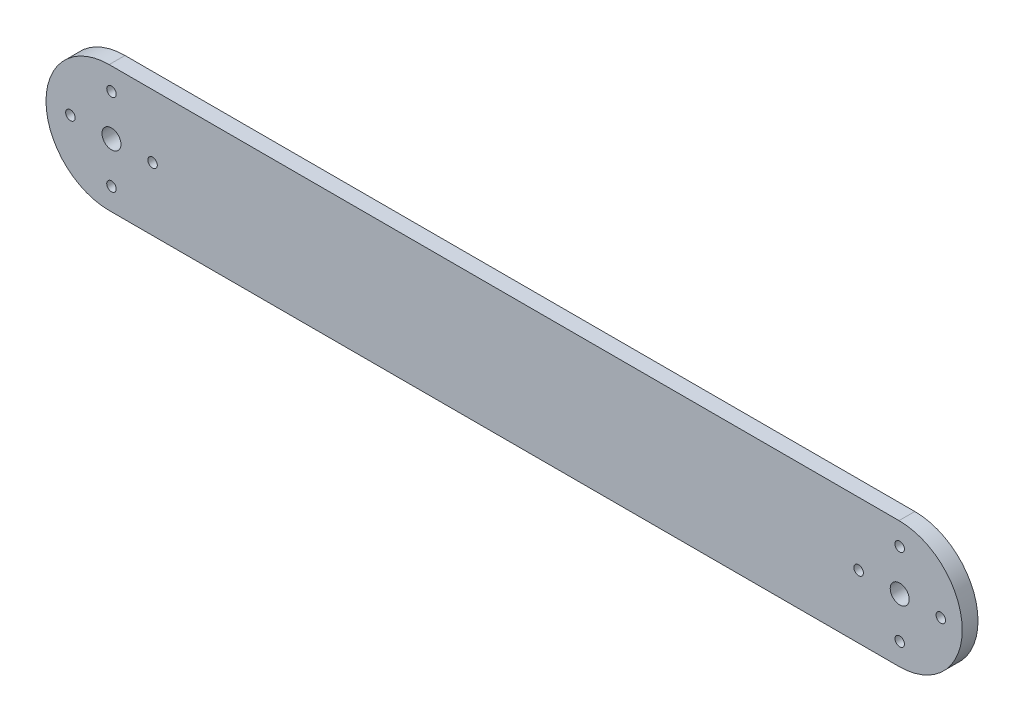
from build123d import *

# Parameters (mm, degrees)
BOSS_EXTRUDE1_DEPTH = 5
SKETCH2_R           = 1.5
CUT_EXTRUDE1_DEPTH  = 5
SKETCH3_R           = 3
CUT_EXTRUDE2_DEPTH  = 5
SKETCH4_R           = 3
CUT_EXTRUDE3_DEPTH  = 10


with BuildPart() as part:
    # Sketch1 → Boss-Extrude1 (new body)
    with BuildSketch(Plane.XY):
        with BuildLine():
            Line((125, -20), (-125, -20))
            ThreePointArc((-125, -20), (-145, 0), (-125, 20))
            Line((-125, 20), (125, 20))
            ThreePointArc((125, 20), (145, 0), (125, -20))
        make_face()
    extrude(amount=BOSS_EXTRUDE1_DEPTH)

    # Sketch2 → Cut-Extrude1 (cut)
    with BuildSketch(Plane.XY.offset(5)):
        with Locations((-124.274977314, 13)):
            Circle(SKETCH2_R)
        with Locations((-111.274977314, 0)):
            Circle(SKETCH2_R)
        with Locations((-124.274977314, -13)):
            Circle(SKETCH2_R)
        with Locations((-137.274977314, 0)):
            Circle(SKETCH2_R)
        with Locations((125.216266839, 13)):
            Circle(SKETCH2_R)
        with Locations((138.216266839, 0)):
            Circle(SKETCH2_R)
        with Locations((125.216266839, -13)):
            Circle(SKETCH2_R)
        with Locations((112.216266839, 0)):
            Circle(SKETCH2_R)
    extrude(amount=-CUT_EXTRUDE1_DEPTH, mode=Mode.SUBTRACT)

    # Sketch3 → Cut-Extrude2 (cut)
    with BuildSketch(Plane(origin=(0, 0, 0), x_dir=(-1, 0, 0), z_dir=(0, 0, -1))):
        with Locations((-125.216266839, 0)):
            Circle(SKETCH3_R)
    extrude(amount=-CUT_EXTRUDE2_DEPTH, mode=Mode.SUBTRACT)

    # Sketch4 → Cut-Extrude3 (cut)
    with BuildSketch(Plane(origin=(0, 0, 0), x_dir=(-1, 0, 0), z_dir=(0, 0, -1))):
        with Locations((124.274977314, 0)):
            Circle(SKETCH4_R)
    extrude(amount=-CUT_EXTRUDE3_DEPTH, mode=Mode.SUBTRACT)


solid = part.part
